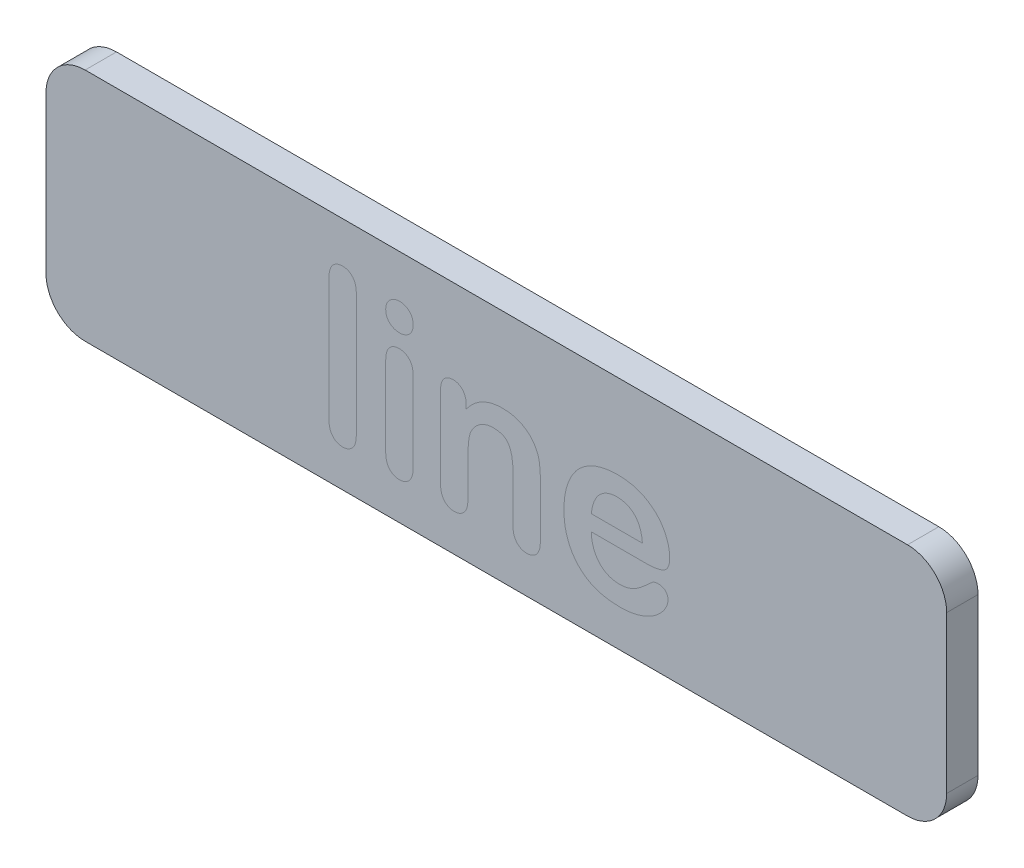
from build123d import *

# Parameters (mm, degrees)
SKETCH1_W             = 6
SKETCH1_H             = 23
BOSS_EXTRUDE1_DEPTH   = 0.8
DIMENSION_CUT_DEPTH   = 0.4
DIMENSION_EXT_DEPTH   = 0.4
DIMENSION_EXT_2_DEPTH = 0.4
DIMENSION_EXT_3_DEPTH = 0.4
DIMENSION_EXT_4_DEPTH = 0.4
DIMENSION_EXT_5_DEPTH = 0.4
FILLET1_R             = 1


with BuildPart() as part:
    # Sketch1 → Boss-Extrude1 (new body)
    with BuildSketch(Plane(origin=(0, 0, 0), x_dir=(0, 1, 0), z_dir=(0, 0, 1))):
        Rectangle(SKETCH1_W, SKETCH1_H)
    extrude(amount=BOSS_EXTRUDE1_DEPTH)

    # Sketch3 → Dimension-Cut (cut)
    # profile 1 of 5: a face of its own
    with BuildSketch(Plane.XY.offset(0.8)):
        with BuildLine():
            Line((-4.275, -1.61171875), (-4.275, 1.51171875))
            add(Edge.make_bspline(
                [(-4.275, 1.51171875), (-4.273806639, 1.545645713), (-4.27155849, 1.609560017), (-4.254857186, 1.699506802), (-4.225464071, 1.776325717), (-4.184222554, 1.839917626), (-4.132350757, 1.889322438), (-4.071936557, 1.925474103), (-4.002600115, 1.94613023), (-3.954042363, 1.948680067), (-3.92890625, 1.95)],
                knots=[0, 0, 0, 0, 1.288703139, 2.427761178, 3.458535653, 4.394326789, 5.283115668, 6.157020003, 7.04597409, 8, 8, 8, 8], degree=3))
            add(Edge.make_bspline(
                [(-3.92890625, 1.95), (-3.903504479, 1.948692645), (-3.854425732, 1.946166706), (-3.784550993, 1.925375176), (-3.723094121, 1.890042852), (-3.669617089, 1.841349595), (-3.626084959, 1.778623751), (-3.595751853, 1.701439324), (-3.578200555, 1.61094206), (-3.576111526, 1.546178174), (-3.575, 1.51171875)],
                knots=[0, 0, 0, 0, 0.955145431, 1.845435904, 2.714968285, 3.603367108, 4.547172696, 5.563135651, 6.703398653, 8, 8, 8, 8], degree=3))
            Line((-3.575, 1.51171875), (-3.575, -1.61171875))
            add(Edge.make_bspline(
                [(-3.575, -1.61171875), (-3.576003749, -1.646202305), (-3.577891752, -1.71106419), (-3.596798275, -1.801313779), (-3.626711065, -1.878863704), (-3.671233559, -1.941448914), (-3.725245708, -1.989566427), (-3.786230733, -2.025612749), (-3.855512178, -2.04596632), (-3.904039967, -2.048633369), (-3.92890625, -2.05)],
                knots=[0, 0, 0, 0, 1.298733371, 2.442854098, 3.460487619, 4.411490617, 5.308636561, 6.171085591, 7.062839985, 8, 8, 8, 8], degree=3))
            add(Edge.make_bspline(
                [(-3.92890625, -2.05), (-3.953553462, -2.048772188), (-4.001230343, -2.046397144), (-4.069290824, -2.024247805), (-4.129408225, -1.98757715), (-4.18175295, -1.937351394), (-4.224833853, -1.873864022), (-4.253519906, -1.796699068), (-4.271934651, -1.708153384), (-4.273937076, -1.645157907), (-4.275, -1.61171875)],
                knots=[0, 0, 0, 0, 0.93838027, 1.815176741, 2.697978161, 3.604673965, 4.563818871, 5.599066837, 6.725540516, 8, 8, 8, 8], degree=3))
        make_face()
    # profile 2 of 5: a face of its own
    with BuildSketch(Plane.XY.offset(0.8)):
        with BuildLine():
            Line((-2.125, 0.4453125), (-2.125, -1.61640625))
            add(Edge.make_bspline(
                [(-2.125, -1.61640625), (-2.126040036, -1.650098169), (-2.128001776, -1.713648687), (-2.146636931, -1.802578326), (-2.1778593, -1.878867834), (-2.221963844, -1.941441392), (-2.276145182, -1.989840279), (-2.337448052, -2.025226252), (-2.406244586, -2.046034272), (-2.454287191, -2.048656341), (-2.47890625, -2.05)],
                knots=[0, 0, 0, 0, 1.279660949, 2.41372764, 3.434282009, 4.393028164, 5.297478756, 6.175532382, 7.06506577, 8, 8, 8, 8], degree=3))
            add(Edge.make_bspline(
                [(-2.47890625, -2.05), (-2.503564255, -2.048790403), (-2.551262014, -2.046450593), (-2.619044964, -2.024092093), (-2.679631798, -1.988486019), (-2.731748616, -1.938081536), (-2.774429783, -1.875013128), (-2.803728814, -1.798887387), (-2.821839891, -1.711523489), (-2.823906576, -1.649317615), (-2.825, -1.61640625)],
                knots=[0, 0, 0, 0, 0.944656094, 1.82731652, 2.710883517, 3.62364324, 4.589202842, 5.612771424, 6.736985008, 8, 8, 8, 8], degree=3))
            Line((-2.825, -1.61640625), (-2.825, 0.42421875))
            add(Edge.make_bspline(
                [(-2.825, 0.42421875), (-2.8238815, 0.45738274), (-2.821766624, 0.520089736), (-2.804099475, 0.607594691), (-2.774574837, 0.68275685), (-2.731698267, 0.743760165), (-2.679267458, 0.791654007), (-2.618933278, 0.825858818), (-2.550989696, 0.846030209), (-2.503523987, 0.848644248), (-2.47890625, 0.85)],
                knots=[0, 0, 0, 0, 1.282601348, 2.425162879, 3.437763456, 4.38569495, 5.284727511, 6.164859808, 7.048218153, 8, 8, 8, 8], degree=3))
            add(Edge.make_bspline(
                [(-2.47890625, 0.85), (-2.454302968, 0.848587528), (-2.406365217, 0.845835428), (-2.337540319, 0.826073645), (-2.276126145, 0.791492041), (-2.222738932, 0.744048135), (-2.17818839, 0.684948451), (-2.147123977, 0.613805779), (-2.128091752, 0.532759335), (-2.12606283, 0.475373481), (-2.125, 0.4453125)],
                knots=[0, 0, 0, 0, 0.975882645, 1.901438153, 2.812865763, 3.75006033, 4.717368935, 5.725761173, 6.808663735, 8, 8, 8, 8], degree=3))
        make_face()
    # profile 3 of 5: a face of its own
    with BuildSketch(Plane.XY.offset(0.8)):
        with BuildLine():
            add(Edge.make_bspline(
                [(-2.47109375, 1.2), (-2.494644119, 1.200921305), (-2.540595503, 1.202718952), (-2.606919295, 1.220680718), (-2.667638679, 1.250047699), (-2.722820266, 1.289631625), (-2.76868703, 1.34077748), (-2.802298317, 1.402685413), (-2.821959534, 1.474343708), (-2.823959436, 1.525135277), (-2.825, 1.5515625)],
                knots=[0, 0, 0, 0, 1.006201835, 1.963296869, 2.915511555, 3.880878732, 4.85189213, 5.829536295, 6.870691953, 8, 8, 8, 8], degree=3))
            add(Edge.make_bspline(
                [(-2.825, 1.5515625), (-2.823618057, 1.575913615), (-2.820939855, 1.623106019), (-2.800906889, 1.690845654), (-2.766465022, 1.751018822), (-2.720165921, 1.803324515), (-2.665131798, 1.845483798), (-2.605071277, 1.878026113), (-2.539331692, 1.896343713), (-2.494117517, 1.898766353), (-2.47109375, 1.9)],
                knots=[0, 0, 0, 0, 1.057408726, 2.04925565, 3.037480321, 4.047814229, 5.064214746, 6.036169889, 6.999986943, 8, 8, 8, 8], degree=3))
            add(Edge.make_bspline(
                [(-2.47109375, 1.9), (-2.448849985, 1.899007497), (-2.405286825, 1.897063736), (-2.341893998, 1.879837598), (-2.28288987, 1.851426233), (-2.229060867, 1.812234993), (-2.18147291, 1.763364873), (-2.148991803, 1.701182419), (-2.127488353, 1.629794436), (-2.125858796, 1.578562387), (-2.125, 1.5515625)],
                knots=[0, 0, 0, 0, 0.967133894, 1.894077239, 2.837452275, 3.803721558, 4.782485793, 5.777084342, 6.828497526, 8, 8, 8, 8], degree=3))
            add(Edge.make_bspline(
                [(-2.125, 1.5515625), (-2.126005999, 1.525375923), (-2.127939029, 1.47505837), (-2.148080266, 1.40430112), (-2.180320529, 1.342049986), (-2.226630375, 1.291532896), (-2.280154111, 1.251111476), (-2.339449132, 1.221541612), (-2.40352663, 1.202561169), (-2.448303385, 1.200863882), (-2.47109375, 1.2)],
                knots=[0, 0, 0, 0, 1.133982342, 2.178948973, 3.165031597, 4.149752721, 5.126395816, 6.06160272, 7.013399203, 8, 8, 8, 8], degree=3))
        make_face()
    # profile 4 of 5: a face of its own
    with BuildSketch(Plane.XY.offset(0.8)):
        with BuildLine():
            Line((-0.76875, 0.45625), (-0.76875, 0.3703125))
            add(Edge.make_bspline(
                [(-0.76875, 0.3703125), (-0.73693784, 0.409502762), (-0.675281657, 0.485458686), (-0.573256841, 0.585519247), (-0.466071523, 0.668322725), (-0.354159373, 0.73594748), (-0.23479156, 0.787450289), (-0.108009515, 0.823821802), (0.027315539, 0.846483216), (0.120220535, 0.848806141), (0.16796875, 0.85)],
                knots=[0, 0, 0, 0, 1.105863122, 2.14330934, 3.124116013, 4.06884223, 5.002046541, 5.964948147, 6.954091843, 8, 8, 8, 8], degree=3))
            add(Edge.make_bspline(
                [(0.16796875, 0.85), (0.214415255, 0.848500193), (0.305277197, 0.845566165), (0.437673107, 0.822547477), (0.562426962, 0.784035284), (0.678733375, 0.730392582), (0.784167145, 0.66251122), (0.877441406, 0.582253482), (0.954964911, 0.487489075), (0.994279624, 0.416293727), (1.0140625, 0.38046875)],
                knots=[0, 0, 0, 0, 1.092012857, 2.136272848, 3.149533556, 4.155305525, 5.139051171, 6.089806823, 7.038804796, 8, 8, 8, 8], degree=3))
            add(Edge.make_bspline(
                [(1.0140625, 0.38046875), (1.025272055, 0.35856452), (1.047715682, 0.314708154), (1.071848785, 0.244540508), (1.091963281, 0.172650914), (1.104926997, 0.096414227), (1.114287904, 0.013987519), (1.120095726, -0.077537017), (1.124067694, -0.179392244), (1.124678887, -0.250776746), (1.125, -0.28828125)],
                knots=[0, 0, 0, 0, 0.860987887, 1.723858877, 2.59364755, 3.474136303, 4.429262975, 5.499190641, 6.686106779, 8, 8, 8, 8], degree=3))
            Line((1.125, -0.28828125), (1.125, -1.61640625))
            add(Edge.make_bspline(
                [(1.125, -1.61640625), (1.123875837, -1.650081926), (1.121757198, -1.713548303), (1.104215987, -1.802530646), (1.073604716, -1.878554498), (1.031252346, -1.941308557), (0.978497387, -1.990017812), (0.918032888, -2.025184071), (0.849775451, -2.04612394), (0.801969429, -2.048682198), (0.77734375, -2.05)],
                knots=[0, 0, 0, 0, 1.287683965, 2.426814984, 3.449942892, 4.403315466, 5.298703094, 6.173625539, 7.059204068, 8, 8, 8, 8], degree=3))
            add(Edge.make_bspline(
                [(0.77734375, -2.05), (0.752174121, -2.048778421), (0.703474756, -2.046414853), (0.634310382, -2.024293519), (0.572759917, -1.988506452), (0.519829132, -1.938149427), (0.476418605, -1.875075838), (0.446075336, -1.799060835), (0.428224168, -1.71150057), (0.426115589, -1.649309685), (0.425, -1.61640625)],
                knots=[0, 0, 0, 0, 0.956888113, 1.851431539, 2.73651156, 3.649202174, 4.61265493, 5.631794413, 6.747049533, 8, 8, 8, 8], degree=3))
            Line((0.425, -1.61640625), (0.425, -0.4265625))
            add(Edge.make_bspline(
                [(0.425, -0.4265625), (0.424719825, -0.397909778), (0.424176904, -0.342386647), (0.419449741, -0.261839098), (0.411748741, -0.186477944), (0.400869031, -0.116325311), (0.387294383, -0.051132691), (0.368802326, 0.008359843), (0.348925097, 0.063191687), (0.325626549, 0.113087407), (0.297333314, 0.157705), (0.262639098, 0.196752924), (0.2207015, 0.228679558), (0.172949622, 0.254775898), (0.11926728, 0.274953577), (0.059289337, 0.289911199), (-0.007065772, 0.298113578), (-0.053364134, 0.299356332), (-0.07734375, 0.3)],
                knots=[0, 0, 0, 0, 1.347407926, 2.611001687, 3.793088521, 4.908587076, 5.948729011, 6.92120119, 7.835727118, 8.690310665, 9.505642719, 10.312189108, 11.132838799, 11.971477223, 12.863082387, 13.822511078, 14.872198764, 16, 16, 16, 16], degree=3))
            add(Edge.make_bspline(
                [(-0.07734375, 0.3), (-0.109492641, 0.298687917), (-0.172942222, 0.296098368), (-0.265895563, 0.274168264), (-0.354116257, 0.237840562), (-0.436522623, 0.187666853), (-0.512025761, 0.126269549), (-0.576542529, 0.052256748), (-0.631401482, -0.031731089), (-0.657704584, -0.094055847), (-0.67109375, -0.12578125)],
                knots=[0, 0, 0, 0, 0.990651567, 1.955166231, 2.927741695, 3.922358355, 4.92102128, 5.916966927, 6.939665927, 8, 8, 8, 8], degree=3))
            add(Edge.make_bspline(
                [(-0.67109375, -0.12578125), (-0.675467681, -0.140571718), (-0.684898494, -0.172462053), (-0.6955326, -0.225523327), (-0.704639154, -0.287071603), (-0.712623545, -0.35740596), (-0.717356219, -0.436434014), (-0.722603632, -0.523896807), (-0.724503454, -0.620044381), (-0.724829843, -0.686979486), (-0.725, -0.721875)],
                knots=[0, 0, 0, 0, 0.61625433, 1.3287312, 2.16048812, 3.103078273, 4.156926102, 5.324424499, 6.605132795, 8, 8, 8, 8], degree=3))
            Line((-0.725, -0.721875), (-0.725, -1.61640625))
            add(Edge.make_bspline(
                [(-0.725, -1.61640625), (-0.725977163, -1.65038094), (-0.727813674, -1.714234097), (-0.747111358, -1.803298637), (-0.776443755, -1.880363645), (-0.821550219, -1.942224165), (-0.874986155, -1.990512088), (-0.9364865, -2.02543192), (-1.005477135, -2.046024927), (-1.054028094, -2.048653225), (-1.07890625, -2.05)],
                knots=[0, 0, 0, 0, 1.287446969, 2.41967039, 3.443922091, 4.393062967, 5.2960435, 6.159191247, 7.056745165, 8, 8, 8, 8], degree=3))
            add(Edge.make_bspline(
                [(-1.07890625, -2.05), (-1.10328943, -2.048750128), (-1.150698293, -2.046319968), (-1.218169655, -2.024341029), (-1.278176548, -1.98796412), (-1.33107195, -1.938439266), (-1.373425899, -1.874785136), (-1.403988026, -1.79910713), (-1.421757023, -1.711486827), (-1.423877903, -1.64930493), (-1.425, -1.61640625)],
                knots=[0, 0, 0, 0, 0.935579112, 1.81907128, 2.69486961, 3.615758504, 4.582227965, 5.61052191, 6.735794854, 8, 8, 8, 8], degree=3))
            Line((-1.425, -1.61640625), (-1.425, 0.4453125))
            add(Edge.make_bspline(
                [(-1.425, 0.4453125), (-1.424118502, 0.477175523), (-1.422457507, 0.537214529), (-1.405932615, 0.620707158), (-1.380273796, 0.692417593), (-1.340924802, 0.750066723), (-1.292051796, 0.794941342), (-1.235004621, 0.827483114), (-1.169449844, 0.846886791), (-1.123313262, 0.848931937), (-1.09921875, 0.85)],
                knots=[0, 0, 0, 0, 1.29464202, 2.439474141, 3.448837032, 4.371523091, 5.248813216, 6.126614955, 7.021637581, 8, 8, 8, 8], degree=3))
            add(Edge.make_bspline(
                [(-1.09921875, 0.85), (-1.084086315, 0.849297938), (-1.054659474, 0.847932693), (-1.011386599, 0.840175049), (-0.970747542, 0.825841468), (-0.93214063, 0.806438091), (-0.897100255, 0.780917818), (-0.86384913, 0.751418344), (-0.837424886, 0.71371491), (-0.812450915, 0.67242852), (-0.793478686, 0.625127736), (-0.777944098, 0.573529563), (-0.770873035, 0.516333597), (-0.769477325, 0.47683388), (-0.76875, 0.45625)],
                knots=[0, 0, 0, 0, 0.943175954, 1.834119198, 2.726833115, 3.619252164, 4.515056339, 5.421956296, 6.372636641, 7.36874147, 8.423244244, 9.537454901, 10.716731755, 12, 12, 12, 12], degree=3))
        make_face()
    # profile 5 of 5: a face of its own
    with BuildSketch(Plane.XY.offset(0.8)):
        with BuildLine():
            Line((3.83359375, -0.75), (2.425, -0.75))
            add(Edge.make_bspline(
                [(2.425, -0.75), (2.42637739, -0.789154103), (2.429076386, -0.865876589), (2.449371775, -0.976914196), (2.47954393, -1.081201151), (2.521620429, -1.177347201), (2.574129069, -1.263679161), (2.633385247, -1.340836837), (2.702116376, -1.405441574), (2.778369996, -1.458161343), (2.860853247, -1.498412813), (2.947443247, -1.528943569), (3.038657428, -1.546023688), (3.100715816, -1.548666436), (3.13203125, -1.55)],
                knots=[0, 0, 0, 0, 1.179639705, 2.311504614, 3.392005435, 4.44652888, 5.46432702, 6.431680492, 7.370191764, 8.295643874, 9.215452015, 10.129041871, 11.055891293, 12, 12, 12, 12], degree=3))
            add(Edge.make_bspline(
                [(3.13203125, -1.55), (3.173265146, -1.548459382), (3.252706692, -1.545491216), (3.368200044, -1.523689249), (3.475414729, -1.483201335), (3.576642804, -1.428228218), (3.670671423, -1.361766909), (3.74651877, -1.301750992), (3.807135142, -1.248058626), (3.858193155, -1.201148824), (3.916559371, -1.148888901), (3.956843079, -1.111276773), (3.978125, -1.09140625)],
                knots=[0, 0, 0, 0, 1.247905556, 2.404224554, 3.538983975, 4.702801183, 5.881313568, 7.020008393, 7.628790321, 8.331868978, 9.11872483, 10, 10, 10, 10], degree=3))
            add(Edge.make_bspline(
                [(3.978125, -1.09140625), (3.988022126, -1.084187905), (4.00862361, -1.069162471), (4.046373036, -1.054660427), (4.089728005, -1.046301739), (4.120530607, -1.045141177), (4.13671875, -1.04453125)],
                knots=[0, 0, 0, 0, 0.868866131, 1.808598965, 2.848320883, 4, 4, 4, 4], degree=3))
            add(Edge.make_bspline(
                [(4.13671875, -1.04453125), (4.154517108, -1.045155398), (4.188459642, -1.046345687), (4.236398999, -1.058835092), (4.279762257, -1.077159287), (4.316588944, -1.105264551), (4.347600612, -1.139234756), (4.369031644, -1.181040042), (4.382856364, -1.22854772), (4.383853959, -1.262654734), (4.384375, -1.28046875)],
                knots=[0, 0, 0, 0, 1.102465736, 2.102468148, 3.057950005, 4.00546365, 4.956145095, 5.889200524, 6.897534264, 8, 8, 8, 8], degree=3))
            add(Edge.make_bspline(
                [(4.384375, -1.28046875), (4.383351951, -1.297730946), (4.381183225, -1.334324475), (4.366163577, -1.390936954), (4.341322473, -1.451156174), (4.307762558, -1.514816534), (4.265273093, -1.580434351), (4.211222153, -1.644334998), (4.148629566, -1.707958343), (4.07590691, -1.769322877), (3.994072896, -1.82806811), (3.901803833, -1.881594452), (3.799111804, -1.928450637), (3.687649926, -1.971935174), (3.566745025, -2.007117233), (3.436468435, -2.031687468), (3.297805804, -2.047900269), (3.20213144, -2.049288777), (3.153125, -2.05)],
                knots=[0, 0, 0, 0, 0.525537938, 1.114069654, 1.772306998, 2.506549159, 3.302753817, 4.147512317, 5.050313588, 6.017967943, 7.041213872, 8.114344659, 9.260276936, 10.47524946, 11.755151616, 13.087980653, 14.508401902, 16, 16, 16, 16], degree=3))
            add(Edge.make_bspline(
                [(3.153125, -2.05), (3.097087469, -2.048787291), (2.987838389, -2.046423031), (2.829123617, -2.028476343), (2.680437397, -1.998345297), (2.542133071, -1.9549881), (2.413318021, -1.900798606), (2.295062075, -1.833020707), (2.187495568, -1.752788061), (2.090103851, -1.661111113), (2.004499159, -1.558242259), (1.928738513, -1.447217505), (1.866336028, -1.326465679), (1.814472402, -1.197528622), (1.7740121, -1.059906798), (1.745218441, -0.913489225), (1.727784937, -0.758498445), (1.725943195, -0.652129831), (1.725, -0.59765625)],
                knots=[0, 0, 0, 0, 1.161895415, 2.265196273, 3.307380836, 4.303185105, 5.266158709, 6.199917451, 7.122316156, 8.043005893, 8.966794753, 9.89246016, 10.824859252, 11.779559524, 12.770652002, 13.794812853, 14.87067777, 16, 16, 16, 16], degree=3))
            add(Edge.make_bspline(
                [(1.725, -0.59765625), (1.725944765, -0.546042471), (1.727806348, -0.444341744), (1.745702708, -0.294681923), (1.773568172, -0.150708415), (1.812308719, -0.012677703), (1.86309269, 0.11707581), (1.92312604, 0.238727215), (1.994807062, 0.349997425), (2.075924428, 0.452389621), (2.168909477, 0.543561035), (2.272909322, 0.623954691), (2.388172186, 0.692635675), (2.514003905, 0.749715986), (2.649028394, 0.795072609), (2.792603365, 0.826473068), (2.943683499, 0.846897298), (3.047066211, 0.848949325), (3.1, 0.85)],
                knots=[0, 0, 0, 0, 1.095507523, 2.15860795, 3.195309999, 4.206995944, 5.197887526, 6.149926361, 7.082497361, 8.003040645, 8.917987058, 9.840388418, 10.787726911, 11.760164811, 12.769081724, 13.806049167, 14.876658106, 16, 16, 16, 16], degree=3))
            add(Edge.make_bspline(
                [(3.1, 0.85), (3.134658201, 0.849723068), (3.202526535, 0.849180775), (3.302356609, 0.83981312), (3.398648706, 0.826857765), (3.49150836, 0.808583552), (3.579991388, 0.783046943), (3.664928976, 0.753436754), (3.746279463, 0.718450114), (3.823346992, 0.677418428), (3.896911693, 0.633544955), (3.964654386, 0.584291281), (4.029120836, 0.534168854), (4.088054303, 0.479486227), (4.14278967, 0.422171099), (4.191788316, 0.360842945), (4.237037372, 0.297295601), (4.28895426, 0.208672506), (4.343313934, 0.094898058), (4.39177961, -0.044816759), (4.421070684, -0.186800559), (4.424735799, -0.282160102), (4.4265625, -0.3296875)],
                knots=[0, 0, 0, 0, 1.048847282, 2.053872234, 3.03283051, 3.989924751, 4.915857681, 5.818505585, 6.711913066, 7.593554535, 8.460263899, 9.302531452, 10.127499996, 10.930978608, 11.734070318, 12.524563272, 13.305443929, 14.093732096, 15.631266151, 17.114748765, 18.561984696, 20, 20, 20, 20], degree=3))
            add(Edge.make_bspline(
                [(4.4265625, -0.3296875), (4.42614406, -0.350800327), (4.425345913, -0.39107169), (4.418497677, -0.448732576), (4.406187012, -0.500430067), (4.388662007, -0.546522002), (4.36744462, -0.587361437), (4.340057105, -0.621660591), (4.308374594, -0.650602427), (4.257229672, -0.681071218), (4.182186405, -0.70942966), (4.079726194, -0.733300956), (3.961871551, -0.747880036), (3.877908737, -0.749267635), (3.83359375, -0.75)],
                knots=[0, 0, 0, 0, 0.899856074, 1.716417764, 2.470354694, 3.159019517, 3.814679391, 4.423252287, 5.02068589, 5.633798556, 6.949059873, 8.421953477, 10.111532063, 12, 12, 12, 12], degree=3))
        make_face()
        with BuildLine():
            Line((2.425, -0.35), (3.73046875, -0.35))
            add(Edge.make_bspline(
                [(3.73046875, -0.35), (3.728085678, -0.321552391), (3.723449561, -0.266209362), (3.708712766, -0.186515152), (3.691391653, -0.112144286), (3.668419242, -0.043460185), (3.641325943, 0.019573864), (3.609849183, 0.077688143), (3.573284154, 0.129737714), (3.532338934, 0.176314938), (3.487307793, 0.217137291), (3.439184177, 0.253201921), (3.386925065, 0.283249428), (3.331139487, 0.307085277), (3.272571865, 0.327232013), (3.210040497, 0.339847804), (3.14455185, 0.349175711), (3.09951531, 0.349721725), (3.0765625, 0.35)],
                knots=[0, 0, 0, 0, 1.274652096, 2.479755284, 3.617009281, 4.684005428, 5.71065458, 6.679155714, 7.63137599, 8.546404667, 9.444107911, 10.342338794, 11.228430864, 12.129821099, 13.049645363, 13.989847955, 14.975528821, 16, 16, 16, 16], degree=3))
            add(Edge.make_bspline(
                [(3.0765625, 0.35), (3.054668477, 0.349284007), (3.011784517, 0.347881586), (2.948637351, 0.340258064), (2.888694507, 0.326231502), (2.831710712, 0.30637724), (2.777681746, 0.281453095), (2.726629868, 0.250778788), (2.678716328, 0.214631141), (2.634081382, 0.172900816), (2.592479522, 0.126199291), (2.555815944, 0.073598363), (2.523803057, 0.015726156), (2.494607322, -0.046664991), (2.470501499, -0.114991924), (2.451271936, -0.188774246), (2.435562743, -0.267566342), (2.428577031, -0.322084167), (2.425, -0.35)],
                knots=[0, 0, 0, 0, 0.988988761, 1.937138454, 2.867098831, 3.763434994, 4.657917626, 5.549380048, 6.447873833, 7.363218941, 8.304708192, 9.267190604, 10.251834605, 11.288414524, 12.374576878, 13.518478699, 14.729337904, 16, 16, 16, 16], degree=3))
        make_face(mode=Mode.SUBTRACT)
    extrude(amount=-DIMENSION_CUT_DEPTH, mode=Mode.SUBTRACT)

    # Fillet1
    fillet1_edges = [part.edges().sort_by_distance(p)[0] for p in [
        (11.5, -3, 0.4),
        (-11.5, -3, 0.4),
        (-11.5, 3, 0.4),
        (11.5, 3, 0.4),
    ]]
    fillet(fillet1_edges, radius=FILLET1_R)


with BuildPart() as body_2:
    # Sketch3_2 → Dimension-Ext (new body)
    with BuildSketch(Plane.XY.offset(0.8)):
        with BuildLine():
            Line((-4.275, -1.61171875), (-4.275, 1.51171875))
            add(Edge.make_bspline(
                [(-4.275, 1.51171875), (-4.273806639, 1.545645713), (-4.27155849, 1.609560017), (-4.254857186, 1.699506802), (-4.225464071, 1.776325717), (-4.184222554, 1.839917626), (-4.132350757, 1.889322438), (-4.071936557, 1.925474103), (-4.002600115, 1.94613023), (-3.954042363, 1.948680067), (-3.92890625, 1.95)],
                knots=[0, 0, 0, 0, 1.288703139, 2.427761178, 3.458535653, 4.394326789, 5.283115668, 6.157020003, 7.04597409, 8, 8, 8, 8], degree=3))
            add(Edge.make_bspline(
                [(-3.92890625, 1.95), (-3.903504479, 1.948692645), (-3.854425732, 1.946166706), (-3.784550993, 1.925375176), (-3.723094121, 1.890042852), (-3.669617089, 1.841349595), (-3.626084959, 1.778623751), (-3.595751853, 1.701439324), (-3.578200555, 1.61094206), (-3.576111526, 1.546178174), (-3.575, 1.51171875)],
                knots=[0, 0, 0, 0, 0.955145431, 1.845435904, 2.714968285, 3.603367108, 4.547172696, 5.563135651, 6.703398653, 8, 8, 8, 8], degree=3))
            Line((-3.575, 1.51171875), (-3.575, -1.61171875))
            add(Edge.make_bspline(
                [(-3.575, -1.61171875), (-3.576003749, -1.646202305), (-3.577891752, -1.71106419), (-3.596798275, -1.801313779), (-3.626711065, -1.878863704), (-3.671233559, -1.941448914), (-3.725245708, -1.989566427), (-3.786230733, -2.025612749), (-3.855512178, -2.04596632), (-3.904039967, -2.048633369), (-3.92890625, -2.05)],
                knots=[0, 0, 0, 0, 1.298733371, 2.442854098, 3.460487619, 4.411490617, 5.308636561, 6.171085591, 7.062839985, 8, 8, 8, 8], degree=3))
            add(Edge.make_bspline(
                [(-3.92890625, -2.05), (-3.953553462, -2.048772188), (-4.001230343, -2.046397144), (-4.069290824, -2.024247805), (-4.129408225, -1.98757715), (-4.18175295, -1.937351394), (-4.224833853, -1.873864022), (-4.253519906, -1.796699068), (-4.271934651, -1.708153384), (-4.273937076, -1.645157907), (-4.275, -1.61171875)],
                knots=[0, 0, 0, 0, 0.93838027, 1.815176741, 2.697978161, 3.604673965, 4.563818871, 5.599066837, 6.725540516, 8, 8, 8, 8], degree=3))
        make_face()
    extrude(amount=-DIMENSION_EXT_DEPTH)


with BuildPart() as body_3:
    # Sketch3_2 → Dimension-Ext 2 (new body)
    with BuildSketch(Plane.XY.offset(0.8)):
        with BuildLine():
            Line((-2.125, 0.4453125), (-2.125, -1.61640625))
            add(Edge.make_bspline(
                [(-2.125, -1.61640625), (-2.126040036, -1.650098169), (-2.128001776, -1.713648687), (-2.146636931, -1.802578326), (-2.1778593, -1.878867834), (-2.221963844, -1.941441392), (-2.276145182, -1.989840279), (-2.337448052, -2.025226252), (-2.406244586, -2.046034272), (-2.454287191, -2.048656341), (-2.47890625, -2.05)],
                knots=[0, 0, 0, 0, 1.279660949, 2.41372764, 3.434282009, 4.393028164, 5.297478756, 6.175532382, 7.06506577, 8, 8, 8, 8], degree=3))
            add(Edge.make_bspline(
                [(-2.47890625, -2.05), (-2.503564255, -2.048790403), (-2.551262014, -2.046450593), (-2.619044964, -2.024092093), (-2.679631798, -1.988486019), (-2.731748616, -1.938081536), (-2.774429783, -1.875013128), (-2.803728814, -1.798887387), (-2.821839891, -1.711523489), (-2.823906576, -1.649317615), (-2.825, -1.61640625)],
                knots=[0, 0, 0, 0, 0.944656094, 1.82731652, 2.710883517, 3.62364324, 4.589202842, 5.612771424, 6.736985008, 8, 8, 8, 8], degree=3))
            Line((-2.825, -1.61640625), (-2.825, 0.42421875))
            add(Edge.make_bspline(
                [(-2.825, 0.42421875), (-2.8238815, 0.45738274), (-2.821766624, 0.520089736), (-2.804099475, 0.607594691), (-2.774574837, 0.68275685), (-2.731698267, 0.743760165), (-2.679267458, 0.791654007), (-2.618933278, 0.825858818), (-2.550989696, 0.846030209), (-2.503523987, 0.848644248), (-2.47890625, 0.85)],
                knots=[0, 0, 0, 0, 1.282601348, 2.425162879, 3.437763456, 4.38569495, 5.284727511, 6.164859808, 7.048218153, 8, 8, 8, 8], degree=3))
            add(Edge.make_bspline(
                [(-2.47890625, 0.85), (-2.454302968, 0.848587528), (-2.406365217, 0.845835428), (-2.337540319, 0.826073645), (-2.276126145, 0.791492041), (-2.222738932, 0.744048135), (-2.17818839, 0.684948451), (-2.147123977, 0.613805779), (-2.128091752, 0.532759335), (-2.12606283, 0.475373481), (-2.125, 0.4453125)],
                knots=[0, 0, 0, 0, 0.975882645, 1.901438153, 2.812865763, 3.75006033, 4.717368935, 5.725761173, 6.808663735, 8, 8, 8, 8], degree=3))
        make_face()
    extrude(amount=-DIMENSION_EXT_2_DEPTH)


with BuildPart() as body_4:
    # Sketch3_2 → Dimension-Ext 3 (new body)
    with BuildSketch(Plane.XY.offset(0.8)):
        with BuildLine():
            add(Edge.make_bspline(
                [(-2.47109375, 1.2), (-2.494644119, 1.200921305), (-2.540595503, 1.202718952), (-2.606919295, 1.220680718), (-2.667638679, 1.250047699), (-2.722820266, 1.289631625), (-2.76868703, 1.34077748), (-2.802298317, 1.402685413), (-2.821959534, 1.474343708), (-2.823959436, 1.525135277), (-2.825, 1.5515625)],
                knots=[0, 0, 0, 0, 1.006201835, 1.963296869, 2.915511555, 3.880878732, 4.85189213, 5.829536295, 6.870691953, 8, 8, 8, 8], degree=3))
            add(Edge.make_bspline(
                [(-2.825, 1.5515625), (-2.823618057, 1.575913615), (-2.820939855, 1.623106019), (-2.800906889, 1.690845654), (-2.766465022, 1.751018822), (-2.720165921, 1.803324515), (-2.665131798, 1.845483798), (-2.605071277, 1.878026113), (-2.539331692, 1.896343713), (-2.494117517, 1.898766353), (-2.47109375, 1.9)],
                knots=[0, 0, 0, 0, 1.057408726, 2.04925565, 3.037480321, 4.047814229, 5.064214746, 6.036169889, 6.999986943, 8, 8, 8, 8], degree=3))
            add(Edge.make_bspline(
                [(-2.47109375, 1.9), (-2.448849985, 1.899007497), (-2.405286825, 1.897063736), (-2.341893998, 1.879837598), (-2.28288987, 1.851426233), (-2.229060867, 1.812234993), (-2.18147291, 1.763364873), (-2.148991803, 1.701182419), (-2.127488353, 1.629794436), (-2.125858796, 1.578562387), (-2.125, 1.5515625)],
                knots=[0, 0, 0, 0, 0.967133894, 1.894077239, 2.837452275, 3.803721558, 4.782485793, 5.777084342, 6.828497526, 8, 8, 8, 8], degree=3))
            add(Edge.make_bspline(
                [(-2.125, 1.5515625), (-2.126005999, 1.525375923), (-2.127939029, 1.47505837), (-2.148080266, 1.40430112), (-2.180320529, 1.342049986), (-2.226630375, 1.291532896), (-2.280154111, 1.251111476), (-2.339449132, 1.221541612), (-2.40352663, 1.202561169), (-2.448303385, 1.200863882), (-2.47109375, 1.2)],
                knots=[0, 0, 0, 0, 1.133982342, 2.178948973, 3.165031597, 4.149752721, 5.126395816, 6.06160272, 7.013399203, 8, 8, 8, 8], degree=3))
        make_face()
    extrude(amount=-DIMENSION_EXT_3_DEPTH)


with BuildPart() as body_5:
    # Sketch3_2 → Dimension-Ext 4 (new body)
    with BuildSketch(Plane.XY.offset(0.8)):
        with BuildLine():
            Line((-0.76875, 0.45625), (-0.76875, 0.3703125))
            add(Edge.make_bspline(
                [(-0.76875, 0.3703125), (-0.73693784, 0.409502762), (-0.675281657, 0.485458686), (-0.573256841, 0.585519247), (-0.466071523, 0.668322725), (-0.354159373, 0.73594748), (-0.23479156, 0.787450289), (-0.108009515, 0.823821802), (0.027315539, 0.846483216), (0.120220535, 0.848806141), (0.16796875, 0.85)],
                knots=[0, 0, 0, 0, 1.105863122, 2.14330934, 3.124116013, 4.06884223, 5.002046541, 5.964948147, 6.954091843, 8, 8, 8, 8], degree=3))
            add(Edge.make_bspline(
                [(0.16796875, 0.85), (0.214415255, 0.848500193), (0.305277197, 0.845566165), (0.437673107, 0.822547477), (0.562426962, 0.784035284), (0.678733375, 0.730392582), (0.784167145, 0.66251122), (0.877441406, 0.582253482), (0.954964911, 0.487489075), (0.994279624, 0.416293727), (1.0140625, 0.38046875)],
                knots=[0, 0, 0, 0, 1.092012857, 2.136272848, 3.149533556, 4.155305525, 5.139051171, 6.089806823, 7.038804796, 8, 8, 8, 8], degree=3))
            add(Edge.make_bspline(
                [(1.0140625, 0.38046875), (1.025272055, 0.35856452), (1.047715682, 0.314708154), (1.071848785, 0.244540508), (1.091963281, 0.172650914), (1.104926997, 0.096414227), (1.114287904, 0.013987519), (1.120095726, -0.077537017), (1.124067694, -0.179392244), (1.124678887, -0.250776746), (1.125, -0.28828125)],
                knots=[0, 0, 0, 0, 0.860987887, 1.723858877, 2.59364755, 3.474136303, 4.429262975, 5.499190641, 6.686106779, 8, 8, 8, 8], degree=3))
            Line((1.125, -0.28828125), (1.125, -1.61640625))
            add(Edge.make_bspline(
                [(1.125, -1.61640625), (1.123875837, -1.650081926), (1.121757198, -1.713548303), (1.104215987, -1.802530646), (1.073604716, -1.878554498), (1.031252346, -1.941308557), (0.978497387, -1.990017812), (0.918032888, -2.025184071), (0.849775451, -2.04612394), (0.801969429, -2.048682198), (0.77734375, -2.05)],
                knots=[0, 0, 0, 0, 1.287683965, 2.426814984, 3.449942892, 4.403315466, 5.298703094, 6.173625539, 7.059204068, 8, 8, 8, 8], degree=3))
            add(Edge.make_bspline(
                [(0.77734375, -2.05), (0.752174121, -2.048778421), (0.703474756, -2.046414853), (0.634310382, -2.024293519), (0.572759917, -1.988506452), (0.519829132, -1.938149427), (0.476418605, -1.875075838), (0.446075336, -1.799060835), (0.428224168, -1.71150057), (0.426115589, -1.649309685), (0.425, -1.61640625)],
                knots=[0, 0, 0, 0, 0.956888113, 1.851431539, 2.73651156, 3.649202174, 4.61265493, 5.631794413, 6.747049533, 8, 8, 8, 8], degree=3))
            Line((0.425, -1.61640625), (0.425, -0.4265625))
            add(Edge.make_bspline(
                [(0.425, -0.4265625), (0.424719825, -0.397909778), (0.424176904, -0.342386647), (0.419449741, -0.261839098), (0.411748741, -0.186477944), (0.400869031, -0.116325311), (0.387294383, -0.051132691), (0.368802326, 0.008359843), (0.348925097, 0.063191687), (0.325626549, 0.113087407), (0.297333314, 0.157705), (0.262639098, 0.196752924), (0.2207015, 0.228679558), (0.172949622, 0.254775898), (0.11926728, 0.274953577), (0.059289337, 0.289911199), (-0.007065772, 0.298113578), (-0.053364134, 0.299356332), (-0.07734375, 0.3)],
                knots=[0, 0, 0, 0, 1.347407926, 2.611001687, 3.793088521, 4.908587076, 5.948729011, 6.92120119, 7.835727118, 8.690310665, 9.505642719, 10.312189108, 11.132838799, 11.971477223, 12.863082387, 13.822511078, 14.872198764, 16, 16, 16, 16], degree=3))
            add(Edge.make_bspline(
                [(-0.07734375, 0.3), (-0.109492641, 0.298687917), (-0.172942222, 0.296098368), (-0.265895563, 0.274168264), (-0.354116257, 0.237840562), (-0.436522623, 0.187666853), (-0.512025761, 0.126269549), (-0.576542529, 0.052256748), (-0.631401482, -0.031731089), (-0.657704584, -0.094055847), (-0.67109375, -0.12578125)],
                knots=[0, 0, 0, 0, 0.990651567, 1.955166231, 2.927741695, 3.922358355, 4.92102128, 5.916966927, 6.939665927, 8, 8, 8, 8], degree=3))
            add(Edge.make_bspline(
                [(-0.67109375, -0.12578125), (-0.675467681, -0.140571718), (-0.684898494, -0.172462053), (-0.6955326, -0.225523327), (-0.704639154, -0.287071603), (-0.712623545, -0.35740596), (-0.717356219, -0.436434014), (-0.722603632, -0.523896807), (-0.724503454, -0.620044381), (-0.724829843, -0.686979486), (-0.725, -0.721875)],
                knots=[0, 0, 0, 0, 0.61625433, 1.3287312, 2.16048812, 3.103078273, 4.156926102, 5.324424499, 6.605132795, 8, 8, 8, 8], degree=3))
            Line((-0.725, -0.721875), (-0.725, -1.61640625))
            add(Edge.make_bspline(
                [(-0.725, -1.61640625), (-0.725977163, -1.65038094), (-0.727813674, -1.714234097), (-0.747111358, -1.803298637), (-0.776443755, -1.880363645), (-0.821550219, -1.942224165), (-0.874986155, -1.990512088), (-0.9364865, -2.02543192), (-1.005477135, -2.046024927), (-1.054028094, -2.048653225), (-1.07890625, -2.05)],
                knots=[0, 0, 0, 0, 1.287446969, 2.41967039, 3.443922091, 4.393062967, 5.2960435, 6.159191247, 7.056745165, 8, 8, 8, 8], degree=3))
            add(Edge.make_bspline(
                [(-1.07890625, -2.05), (-1.10328943, -2.048750128), (-1.150698293, -2.046319968), (-1.218169655, -2.024341029), (-1.278176548, -1.98796412), (-1.33107195, -1.938439266), (-1.373425899, -1.874785136), (-1.403988026, -1.79910713), (-1.421757023, -1.711486827), (-1.423877903, -1.64930493), (-1.425, -1.61640625)],
                knots=[0, 0, 0, 0, 0.935579112, 1.81907128, 2.69486961, 3.615758504, 4.582227965, 5.61052191, 6.735794854, 8, 8, 8, 8], degree=3))
            Line((-1.425, -1.61640625), (-1.425, 0.4453125))
            add(Edge.make_bspline(
                [(-1.425, 0.4453125), (-1.424118502, 0.477175523), (-1.422457507, 0.537214529), (-1.405932615, 0.620707158), (-1.380273796, 0.692417593), (-1.340924802, 0.750066723), (-1.292051796, 0.794941342), (-1.235004621, 0.827483114), (-1.169449844, 0.846886791), (-1.123313262, 0.848931937), (-1.09921875, 0.85)],
                knots=[0, 0, 0, 0, 1.29464202, 2.439474141, 3.448837032, 4.371523091, 5.248813216, 6.126614955, 7.021637581, 8, 8, 8, 8], degree=3))
            add(Edge.make_bspline(
                [(-1.09921875, 0.85), (-1.084086315, 0.849297938), (-1.054659474, 0.847932693), (-1.011386599, 0.840175049), (-0.970747542, 0.825841468), (-0.93214063, 0.806438091), (-0.897100255, 0.780917818), (-0.86384913, 0.751418344), (-0.837424886, 0.71371491), (-0.812450915, 0.67242852), (-0.793478686, 0.625127736), (-0.777944098, 0.573529563), (-0.770873035, 0.516333597), (-0.769477325, 0.47683388), (-0.76875, 0.45625)],
                knots=[0, 0, 0, 0, 0.943175954, 1.834119198, 2.726833115, 3.619252164, 4.515056339, 5.421956296, 6.372636641, 7.36874147, 8.423244244, 9.537454901, 10.716731755, 12, 12, 12, 12], degree=3))
        make_face()
    extrude(amount=-DIMENSION_EXT_4_DEPTH)


with BuildPart() as body_6:
    # Sketch3_2 → Dimension-Ext 5 (new body)
    with BuildSketch(Plane.XY.offset(0.8)):
        with BuildLine():
            Line((3.83359375, -0.75), (2.425, -0.75))
            add(Edge.make_bspline(
                [(2.425, -0.75), (2.42637739, -0.789154103), (2.429076386, -0.865876589), (2.449371775, -0.976914196), (2.47954393, -1.081201151), (2.521620429, -1.177347201), (2.574129069, -1.263679161), (2.633385247, -1.340836837), (2.702116376, -1.405441574), (2.778369996, -1.458161343), (2.860853247, -1.498412813), (2.947443247, -1.528943569), (3.038657428, -1.546023688), (3.100715816, -1.548666436), (3.13203125, -1.55)],
                knots=[0, 0, 0, 0, 1.179639705, 2.311504614, 3.392005435, 4.44652888, 5.46432702, 6.431680492, 7.370191764, 8.295643874, 9.215452015, 10.129041871, 11.055891293, 12, 12, 12, 12], degree=3))
            add(Edge.make_bspline(
                [(3.13203125, -1.55), (3.173265146, -1.548459382), (3.252706692, -1.545491216), (3.368200044, -1.523689249), (3.475414729, -1.483201335), (3.576642804, -1.428228218), (3.670671423, -1.361766909), (3.74651877, -1.301750992), (3.807135142, -1.248058626), (3.858193155, -1.201148824), (3.916559371, -1.148888901), (3.956843079, -1.111276773), (3.978125, -1.09140625)],
                knots=[0, 0, 0, 0, 1.247905556, 2.404224554, 3.538983975, 4.702801183, 5.881313568, 7.020008393, 7.628790321, 8.331868978, 9.11872483, 10, 10, 10, 10], degree=3))
            add(Edge.make_bspline(
                [(3.978125, -1.09140625), (3.988022126, -1.084187905), (4.00862361, -1.069162471), (4.046373036, -1.054660427), (4.089728005, -1.046301739), (4.120530607, -1.045141177), (4.13671875, -1.04453125)],
                knots=[0, 0, 0, 0, 0.868866131, 1.808598965, 2.848320883, 4, 4, 4, 4], degree=3))
            add(Edge.make_bspline(
                [(4.13671875, -1.04453125), (4.154517108, -1.045155398), (4.188459642, -1.046345687), (4.236398999, -1.058835092), (4.279762257, -1.077159287), (4.316588944, -1.105264551), (4.347600612, -1.139234756), (4.369031644, -1.181040042), (4.382856364, -1.22854772), (4.383853959, -1.262654734), (4.384375, -1.28046875)],
                knots=[0, 0, 0, 0, 1.102465736, 2.102468148, 3.057950005, 4.00546365, 4.956145095, 5.889200524, 6.897534264, 8, 8, 8, 8], degree=3))
            add(Edge.make_bspline(
                [(4.384375, -1.28046875), (4.383351951, -1.297730946), (4.381183225, -1.334324475), (4.366163577, -1.390936954), (4.341322473, -1.451156174), (4.307762558, -1.514816534), (4.265273093, -1.580434351), (4.211222153, -1.644334998), (4.148629566, -1.707958343), (4.07590691, -1.769322877), (3.994072896, -1.82806811), (3.901803833, -1.881594452), (3.799111804, -1.928450637), (3.687649926, -1.971935174), (3.566745025, -2.007117233), (3.436468435, -2.031687468), (3.297805804, -2.047900269), (3.20213144, -2.049288777), (3.153125, -2.05)],
                knots=[0, 0, 0, 0, 0.525537938, 1.114069654, 1.772306998, 2.506549159, 3.302753817, 4.147512317, 5.050313588, 6.017967943, 7.041213872, 8.114344659, 9.260276936, 10.47524946, 11.755151616, 13.087980653, 14.508401902, 16, 16, 16, 16], degree=3))
            add(Edge.make_bspline(
                [(3.153125, -2.05), (3.097087469, -2.048787291), (2.987838389, -2.046423031), (2.829123617, -2.028476343), (2.680437397, -1.998345297), (2.542133071, -1.9549881), (2.413318021, -1.900798606), (2.295062075, -1.833020707), (2.187495568, -1.752788061), (2.090103851, -1.661111113), (2.004499159, -1.558242259), (1.928738513, -1.447217505), (1.866336028, -1.326465679), (1.814472402, -1.197528622), (1.7740121, -1.059906798), (1.745218441, -0.913489225), (1.727784937, -0.758498445), (1.725943195, -0.652129831), (1.725, -0.59765625)],
                knots=[0, 0, 0, 0, 1.161895415, 2.265196273, 3.307380836, 4.303185105, 5.266158709, 6.199917451, 7.122316156, 8.043005893, 8.966794753, 9.89246016, 10.824859252, 11.779559524, 12.770652002, 13.794812853, 14.87067777, 16, 16, 16, 16], degree=3))
            add(Edge.make_bspline(
                [(1.725, -0.59765625), (1.725944765, -0.546042471), (1.727806348, -0.444341744), (1.745702708, -0.294681923), (1.773568172, -0.150708415), (1.812308719, -0.012677703), (1.86309269, 0.11707581), (1.92312604, 0.238727215), (1.994807062, 0.349997425), (2.075924428, 0.452389621), (2.168909477, 0.543561035), (2.272909322, 0.623954691), (2.388172186, 0.692635675), (2.514003905, 0.749715986), (2.649028394, 0.795072609), (2.792603365, 0.826473068), (2.943683499, 0.846897298), (3.047066211, 0.848949325), (3.1, 0.85)],
                knots=[0, 0, 0, 0, 1.095507523, 2.15860795, 3.195309999, 4.206995944, 5.197887526, 6.149926361, 7.082497361, 8.003040645, 8.917987058, 9.840388418, 10.787726911, 11.760164811, 12.769081724, 13.806049167, 14.876658106, 16, 16, 16, 16], degree=3))
            add(Edge.make_bspline(
                [(3.1, 0.85), (3.134658201, 0.849723068), (3.202526535, 0.849180775), (3.302356609, 0.83981312), (3.398648706, 0.826857765), (3.49150836, 0.808583552), (3.579991388, 0.783046943), (3.664928976, 0.753436754), (3.746279463, 0.718450114), (3.823346992, 0.677418428), (3.896911693, 0.633544955), (3.964654386, 0.584291281), (4.029120836, 0.534168854), (4.088054303, 0.479486227), (4.14278967, 0.422171099), (4.191788316, 0.360842945), (4.237037372, 0.297295601), (4.28895426, 0.208672506), (4.343313934, 0.094898058), (4.39177961, -0.044816759), (4.421070684, -0.186800559), (4.424735799, -0.282160102), (4.4265625, -0.3296875)],
                knots=[0, 0, 0, 0, 1.048847282, 2.053872234, 3.03283051, 3.989924751, 4.915857681, 5.818505585, 6.711913066, 7.593554535, 8.460263899, 9.302531452, 10.127499996, 10.930978608, 11.734070318, 12.524563272, 13.305443929, 14.093732096, 15.631266151, 17.114748765, 18.561984696, 20, 20, 20, 20], degree=3))
            add(Edge.make_bspline(
                [(4.4265625, -0.3296875), (4.42614406, -0.350800327), (4.425345913, -0.39107169), (4.418497677, -0.448732576), (4.406187012, -0.500430067), (4.388662007, -0.546522002), (4.36744462, -0.587361437), (4.340057105, -0.621660591), (4.308374594, -0.650602427), (4.257229672, -0.681071218), (4.182186405, -0.70942966), (4.079726194, -0.733300956), (3.961871551, -0.747880036), (3.877908737, -0.749267635), (3.83359375, -0.75)],
                knots=[0, 0, 0, 0, 0.899856074, 1.716417764, 2.470354694, 3.159019517, 3.814679391, 4.423252287, 5.02068589, 5.633798556, 6.949059873, 8.421953477, 10.111532063, 12, 12, 12, 12], degree=3))
        make_face()
        with BuildLine():
            Line((2.425, -0.35), (3.73046875, -0.35))
            add(Edge.make_bspline(
                [(3.73046875, -0.35), (3.728085678, -0.321552391), (3.723449561, -0.266209362), (3.708712766, -0.186515152), (3.691391653, -0.112144286), (3.668419242, -0.043460185), (3.641325943, 0.019573864), (3.609849183, 0.077688143), (3.573284154, 0.129737714), (3.532338934, 0.176314938), (3.487307793, 0.217137291), (3.439184177, 0.253201921), (3.386925065, 0.283249428), (3.331139487, 0.307085277), (3.272571865, 0.327232013), (3.210040497, 0.339847804), (3.14455185, 0.349175711), (3.09951531, 0.349721725), (3.0765625, 0.35)],
                knots=[0, 0, 0, 0, 1.274652096, 2.479755284, 3.617009281, 4.684005428, 5.71065458, 6.679155714, 7.63137599, 8.546404667, 9.444107911, 10.342338794, 11.228430864, 12.129821099, 13.049645363, 13.989847955, 14.975528821, 16, 16, 16, 16], degree=3))
            add(Edge.make_bspline(
                [(3.0765625, 0.35), (3.054668477, 0.349284007), (3.011784517, 0.347881586), (2.948637351, 0.340258064), (2.888694507, 0.326231502), (2.831710712, 0.30637724), (2.777681746, 0.281453095), (2.726629868, 0.250778788), (2.678716328, 0.214631141), (2.634081382, 0.172900816), (2.592479522, 0.126199291), (2.555815944, 0.073598363), (2.523803057, 0.015726156), (2.494607322, -0.046664991), (2.470501499, -0.114991924), (2.451271936, -0.188774246), (2.435562743, -0.267566342), (2.428577031, -0.322084167), (2.425, -0.35)],
                knots=[0, 0, 0, 0, 0.988988761, 1.937138454, 2.867098831, 3.763434994, 4.657917626, 5.549380048, 6.447873833, 7.363218941, 8.304708192, 9.267190604, 10.251834605, 11.288414524, 12.374576878, 13.518478699, 14.729337904, 16, 16, 16, 16], degree=3))
        make_face(mode=Mode.SUBTRACT)
    extrude(amount=-DIMENSION_EXT_5_DEPTH)


solid = Compound([part.part, body_2.part, body_3.part, body_4.part, body_5.part, body_6.part])
